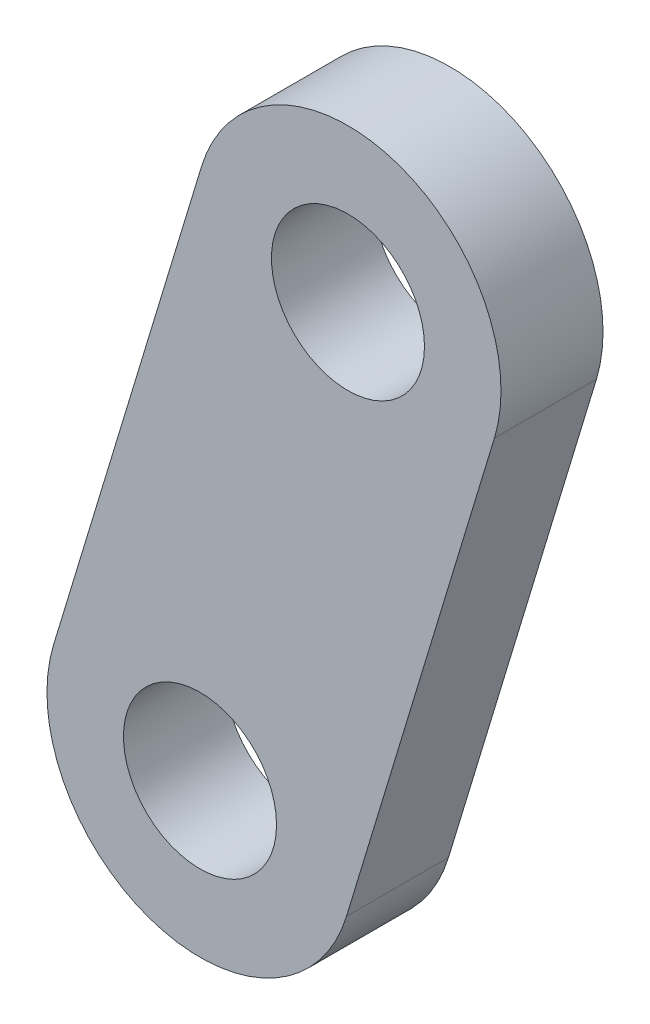
from build123d import *

# Parameters (mm, degrees)
SKETCH1_R           = 7.5
BOSS_EXTRUDE2_DEPTH = 10


with BuildPart() as part:
    # Sketch1 → Boss-Extrude2 (new body)
    with BuildSketch(Plane.XY):
        with BuildLine():
            Line((-14.355366067, 4.350110929), (0.145003698, 52.201331151))
            ThreePointArc((0.145003698, 52.201331151), (18.850480693, 62.206586288), (28.855735831, 43.501109292))
            Line((28.855735831, 43.501109292), (14.355366067, -4.350110929))
            ThreePointArc((14.355366067, -4.350110929), (-4.350110929, -14.355366067), (-14.355366067, 4.350110929))
        make_face()
        Circle(SKETCH1_R, mode=Mode.SUBTRACT)
        with Locations((14.500369764, 47.851220222)):
            Circle(SKETCH1_R, mode=Mode.SUBTRACT)
    extrude(amount=BOSS_EXTRUDE2_DEPTH)


solid = part.part
